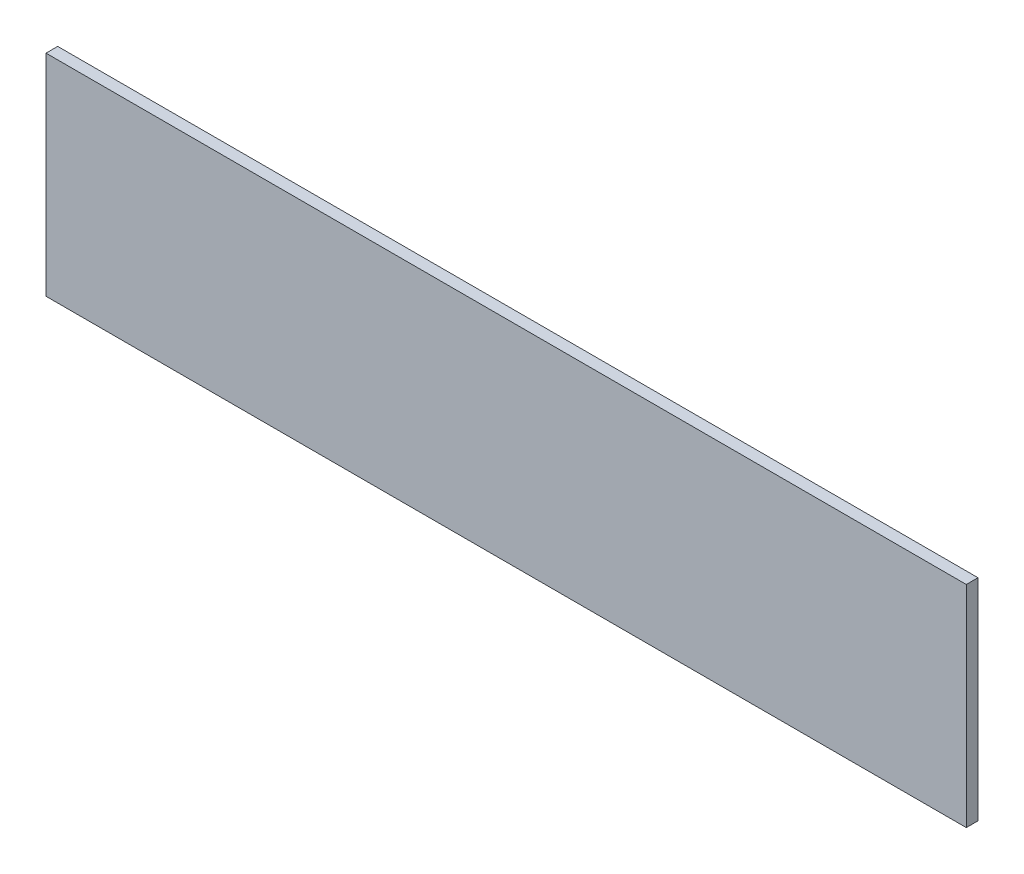
from build123d import *

# Parameters (mm, degrees)
SKETCH1_W           = 59.944
SKETCH1_H           = 13.716
BOSS_EXTRUDE1_DEPTH = 0.762


with BuildPart() as part:
    # Sketch1 → Boss-Extrude1 (new body)
    with BuildSketch(Plane.XY):
        with Locations((-137.237805359, -177.626597764)):
            Rectangle(SKETCH1_W, SKETCH1_H)
    extrude(amount=BOSS_EXTRUDE1_DEPTH)


solid = part.part
